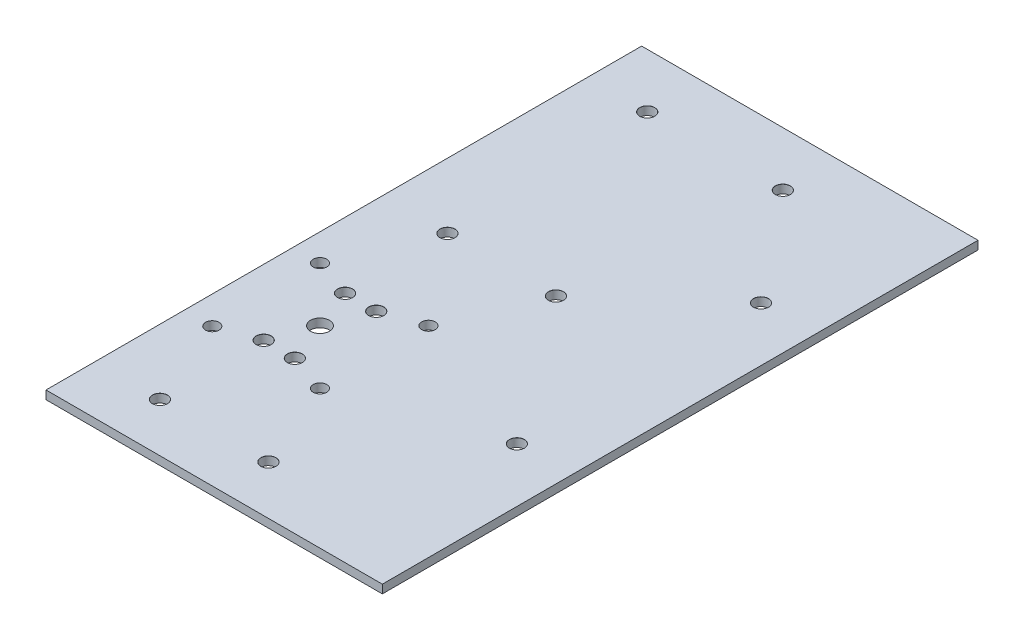
from build123d import *

# Parameters (mm, degrees)
SKETCH1_W                      = 124
SKETCH1_H                      = 219.6
SKETCH1_R                      = 3.5
BOSS_EXTRUDE1_DEPTH            = 3.125
SKETCH2_R                      = 2.5
CUT_EXTRUDE1_DEPTH             = 10
M5_CLEARANCE_HOLE1_D           = 5.5
M5_CLEARANCE_HOLE1_DEPTH       = 10.1
M5_CLEARANCE_HOLE1_CSINK_D     = 5.55
M5_CLEARANCE_HOLE1_CSINK_ANGLE = 90
M5_CLEARANCE_HOLE1_TIP         = 1.652366702
M5_CLEARANCE_HOLE2_D           = 5.5
M5_CLEARANCE_HOLE2_DEPTH       = 10.1
M5_CLEARANCE_HOLE2_CSINK_D     = 5.55
M5_CLEARANCE_HOLE2_CSINK_ANGLE = 90
M5_CLEARANCE_HOLE2_TIP         = 1.652366702
M5_CLEARANCE_HOLE3_D           = 5.5
M5_CLEARANCE_HOLE3_CSINK_D     = 5.55
M5_CLEARANCE_HOLE3_CSINK_ANGLE = 90


with BuildPart() as part:
    # Sketch1 → Boss-Extrude1 (new body)
    with BuildSketch(Plane(origin=(0, 0, 0), x_dir=(1, 0, 0), z_dir=(0, 1, 0))):
        with Locations((62, 109.8)):
            Rectangle(SKETCH1_W, SKETCH1_H)
        with Locations((30, 71)):
            Circle(SKETCH1_R, mode=Mode.SUBTRACT)
    extrude(amount=BOSS_EXTRUDE1_DEPTH)

    # Sketch2 → Cut-Extrude1 (cut)
    with BuildSketch(Plane(origin=(0, 3.125, 0), x_dir=(1, 0, 0), z_dir=(0, 1, 0))):
        with Locations((10.312672757, 51)):
            Circle(SKETCH2_R)
        with Locations((50, 51)):
            Circle(SKETCH2_R)
        with Locations((50, 91)):
            Circle(SKETCH2_R)
        with Locations((10, 91)):
            Circle(SKETCH2_R)
    extrude(amount=-CUT_EXTRUDE1_DEPTH, mode=Mode.SUBTRACT)

    # M5 Clearance Hole1
    with Locations(Plane(origin=(0, 3.125, 0), x_dir=(1, 0, 0), z_dir=(0, 1, 0))):
        with Locations((24.25, 86), (35.75, 86), (35.75, 56), (24.25, 56)):
            CounterSinkHole(M5_CLEARANCE_HOLE1_D / 2, M5_CLEARANCE_HOLE1_CSINK_D / 2, depth=M5_CLEARANCE_HOLE1_DEPTH, counter_sink_angle=M5_CLEARANCE_HOLE1_CSINK_ANGLE)
            with Locations((0, 0, -(M5_CLEARANCE_HOLE1_DEPTH + M5_CLEARANCE_HOLE1_TIP / 2))):  # 118° drill point
                Cone(0, M5_CLEARANCE_HOLE1_D / 2, M5_CLEARANCE_HOLE1_TIP, mode=Mode.SUBTRACT)

    # M5 Clearance Hole2
    with Locations(Plane(origin=(0, 3.125, 0), x_dir=(1, 0, 0), z_dir=(0, 1, 0))):
        with Locations((22.049589497, 199.6), (72.049589497, 199.6), (104, 159.6), (104, 69.6)):
            CounterSinkHole(M5_CLEARANCE_HOLE2_D / 2, M5_CLEARANCE_HOLE2_CSINK_D / 2, depth=M5_CLEARANCE_HOLE2_DEPTH, counter_sink_angle=M5_CLEARANCE_HOLE2_CSINK_ANGLE)
            with Locations((0, 0, -(M5_CLEARANCE_HOLE2_DEPTH + M5_CLEARANCE_HOLE2_TIP / 2))):  # 118° drill point
                Cone(0, M5_CLEARANCE_HOLE2_D / 2, M5_CLEARANCE_HOLE2_TIP, mode=Mode.SUBTRACT)

    # M5 Clearance Hole3 (through all)
    with Locations(Plane(origin=(0, 3.125, 0), x_dir=(1, 0, 0), z_dir=(0, 1, 0))):
        with Locations((24, 124), (64, 124), (24, 18), (64, 18)):
            CounterSinkHole(M5_CLEARANCE_HOLE3_D / 2, M5_CLEARANCE_HOLE3_CSINK_D / 2, counter_sink_angle=M5_CLEARANCE_HOLE3_CSINK_ANGLE)


solid = part.part
